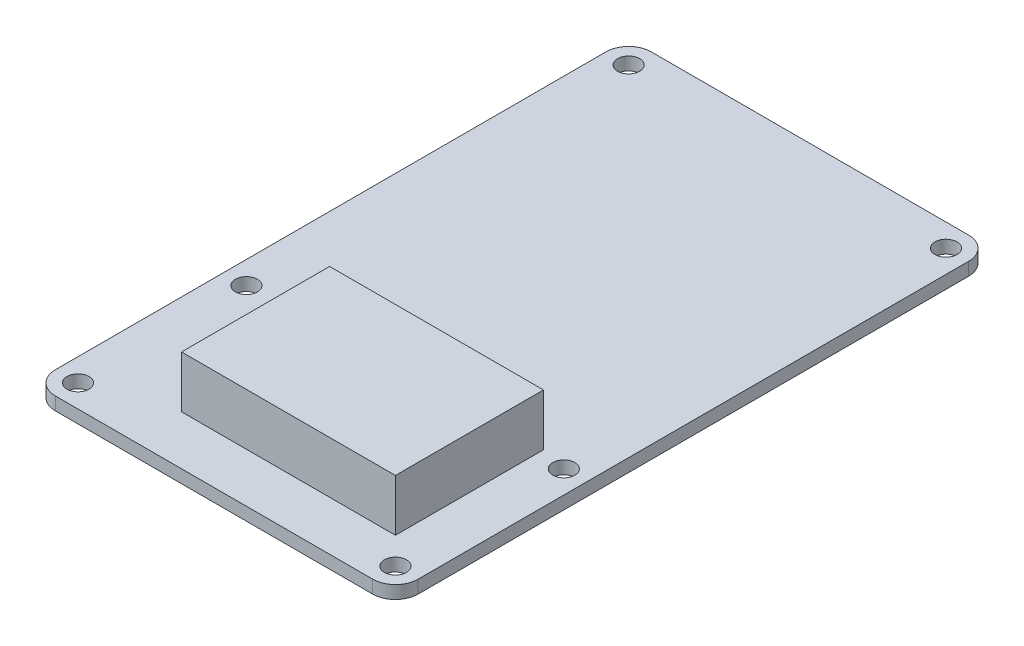
from build123d import *

# Parameters (mm, degrees)
BOSS_EXTRUDE1_DEPTH  = 2
SKETCH2_W            = 33.02
SKETCH2_H            = 22.86
BOSS_EXTRUDE2_DEPTH  = 10
M3_CLEARANCE_HOLE1_D = 3.4


with BuildPart() as part:
    # Sketch1 → Boss-Extrude1 (new body)
    with BuildSketch(Plane(origin=(0, 0, 0), x_dir=(1, 0, 0), z_dir=(0, 1, 0))):
        with BuildLine():
            Line((24.5, 46), (-24.5, 46))
            ThreePointArc((-24.5, 46), (-26.974873734, 44.974873734), (-28, 42.5))
            Line((-28, 42.5), (-28, -42.5))
            ThreePointArc((-28, -42.5), (-26.974873734, -44.974873734), (-24.5, -46))
            Line((-24.5, -46), (24.5, -46))
            ThreePointArc((24.5, -46), (26.974873734, -44.974873734), (28, -42.5))
            Line((28, -42.5), (28, 42.5))
            ThreePointArc((28, 42.5), (26.974873734, 44.974873734), (24.5, 46))
        make_face()
    extrude(amount=BOSS_EXTRUDE1_DEPTH)

    # Sketch2 → Boss-Extrude2 (add)
    with BuildSketch(Plane.XZ):
        with Locations((3.87, 26.95)):
            Rectangle(SKETCH2_W, SKETCH2_H)
    extrude(amount=-BOSS_EXTRUDE2_DEPTH)

    # M3 Clearance Hole1 (through all)
    with Locations(Plane(origin=(0, 0, 0), x_dir=(-1, 0, 0), z_dir=(0, -1, 0))):
        with Locations((-24.5, -42.5), (24.5, -42.5), (24.5, -16.5), (-24.5, -16.5), (-24.5, 42.5), (24.5, 42.5)):
            Hole(M3_CLEARANCE_HOLE1_D / 2)


solid = part.part
